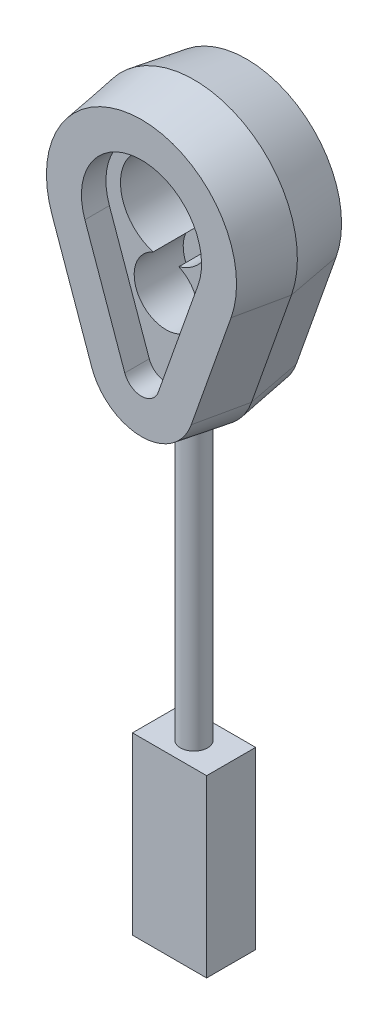
from build123d import *

# Parameters (mm, degrees)
BOSS_EXTRUDE3_DEPTH           = 3.81
BOSS_EXTRUDE3_TAPER           = 9
BOSS_EXTRUDE3_OTHER_WAY_DEPTH = 3.81
BOSS_EXTRUDE3_OTHER_WAY_TAPER = 9
CUT_EXTRUDE1_DEPTH            = 1.778
CUT_EXTRUDE2_DEPTH            = 3.556
BOSS_EXTRUDE4_REACH           = 43.527
SKETCH6_R                     = 0.984091707
SKETCH7_W                     = 5.381079671
SKETCH7_H                     = 12.713539883
BOSS_EXTRUDE5_DEPTH           = 1.778


with BuildPart() as part:
    # Sketch1 → Boss-Extrude3 (new body)
    with BuildSketch(Plane.XY):
        with BuildLine():
            Line((-7.070417047, 6.599948555), (-4.176993685, -1.577117469))
            ThreePointArc((-4.176993685, -1.577117469), (0, -4.529882932), (4.176993685, -1.577117469))
            Line((4.176993685, -1.577117469), (7.070417047, 6.599948555))
            ThreePointArc((7.070417047, 6.599948555), (0, 16.601788433), (-7.070417047, 6.599948555))
        make_face()
    extrude(amount=BOSS_EXTRUDE3_DEPTH, taper=BOSS_EXTRUDE3_TAPER)

    # Sketch1 → Boss-Extrude3 other way (add)
    with BuildSketch(Plane.XY):
        with BuildLine():
            Line((-7.070417047, 6.599948555), (-4.176993685, -1.577117469))
            ThreePointArc((-4.176993685, -1.577117469), (0, -4.529882932), (4.176993685, -1.577117469))
            Line((4.176993685, -1.577117469), (7.070417047, 6.599948555))
            ThreePointArc((7.070417047, 6.599948555), (0, 16.601788433), (-7.070417047, 6.599948555))
        make_face()
    extrude(amount=-BOSS_EXTRUDE3_OTHER_WAY_DEPTH, taper=BOSS_EXTRUDE3_OTHER_WAY_TAPER)

    # Sketch3 → Cut-Extrude1 (cut)
    with BuildSketch(Plane.XY.offset(3.81)):
        with BuildLine():
            Line((-4.107021698, 7.648534601), (-1.213598336, -0.528531422))
            ThreePointArc((-1.213598336, -0.528531422), (0, -1.386438214), (1.213598336, -0.528531422))
            Line((1.213598336, -0.528531422), (4.107021698, 7.648534601))
            ThreePointArc((4.107021698, 7.648534601), (0, 13.458343715), (-4.107021698, 7.648534601))
        make_face()
    extrude(amount=-CUT_EXTRUDE1_DEPTH, mode=Mode.SUBTRACT)

    # Sketch4 → Cut-Extrude2 (cut)
    with BuildSketch(Plane.XY.offset(2.032)):
        with BuildLine():
            ThreePointArc((0.9304508, 6.328323332), (0, 12.801349411), (-0.9304508, 6.328323332))
            ThreePointArc((-0.9304508, 6.328323332), (0, 1.908170612), (0.9304508, 6.328323332))
        make_face()
    extrude(amount=-CUT_EXTRUDE2_DEPTH, mode=Mode.SUBTRACT)

    # Sketch6 → Boss-Extrude4 (add, up to next)
    with BuildSketch(Plane(origin=(0, -24.925590476, 0), x_dir=(1, 0, 0), z_dir=(0, 1, 0)), mode=Mode.PRIVATE) as boss_extrude4_sk1:
        Circle(SKETCH6_R)
    boss_extrude4_tool1 = extrude(boss_extrude4_sk1.sketch, amount=BOSS_EXTRUDE4_REACH, mode=Mode.PRIVATE) - part.part
    add(boss_extrude4_tool1.solids().sort_by_distance((0, -24.92559, 0))[0])

    # Sketch7 → Boss-Extrude5 (add, symmetric)
    with BuildSketch(Plane.XY):
        with Locations((0.003481044, -31.250797668)):
            Rectangle(SKETCH7_W, SKETCH7_H)
    extrude(amount=BOSS_EXTRUDE5_DEPTH, both=True)


solid = part.part
